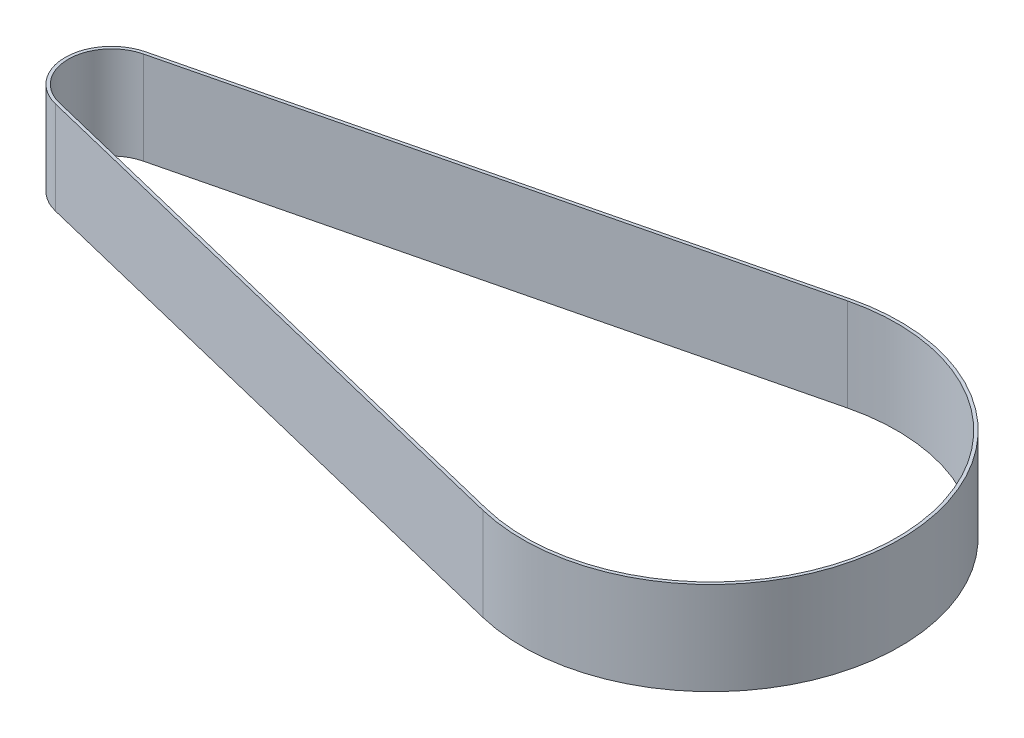
from build123d import *

# Parameters (mm, degrees)
BOSS_EXTRUDE1_DEPTH = 15


with BuildPart() as part:
    # Sketch1 → Boss-Extrude1 (new body)
    with BuildSketch(Plane(origin=(0, 0, 0), x_dir=(1, 0, 0), z_dir=(0, 1, 0))):
        with BuildLine():
            Line((-182.741668224, 151.970903781), (-274.185945777, 129.628146904))
            ThreePointArc((-274.185945777, 129.628146904), (-279.905821128, 122.342465314), (-274.185945777, 115.056783724))
            Line((-274.185945777, 115.056783724), (-182.741668224, 92.714026847))
            ThreePointArc((-182.741668224, 92.714026847), (-145.002494652, 122.342465314), (-182.741668224, 151.970903781))
        make_face()
        with BuildLine():
            Line((-274.0672708, 129.142434798), (-182.622993247, 151.485191675))
            ThreePointArc((-182.622993247, 151.485191675), (-145.502494652, 122.342465314), (-182.622993247, 93.199738953))
            Line((-182.622993247, 93.199738953), (-274.0672708, 115.54249583))
            ThreePointArc((-274.0672708, 115.54249583), (-279.405821128, 122.342465314), (-274.0672708, 129.142434798))
        make_face(mode=Mode.SUBTRACT)
    extrude(amount=BOSS_EXTRUDE1_DEPTH)


solid = part.part
